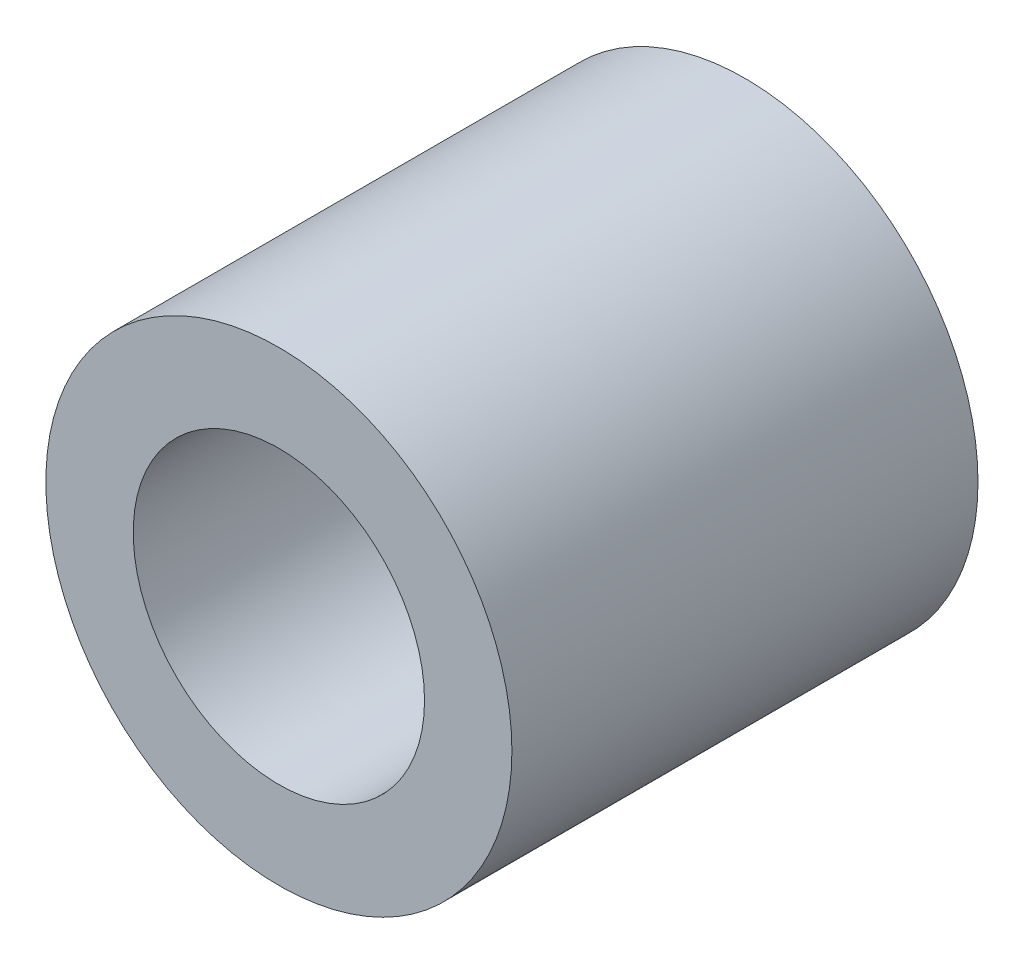
from build123d import *

# Parameters (mm, degrees)
ESQUISSE1_R        = 8
ESQUISSE1_R_2      = 5
BOSS_EXTRU_1_DEPTH = 16


with BuildPart() as part:
    # Esquisse1 → Boss.-Extru.1 (new body)
    with BuildSketch(Plane.XY):
        Circle(ESQUISSE1_R)
        Circle(ESQUISSE1_R_2, mode=Mode.SUBTRACT)
    extrude(amount=BOSS_EXTRU_1_DEPTH)


solid = part.part
